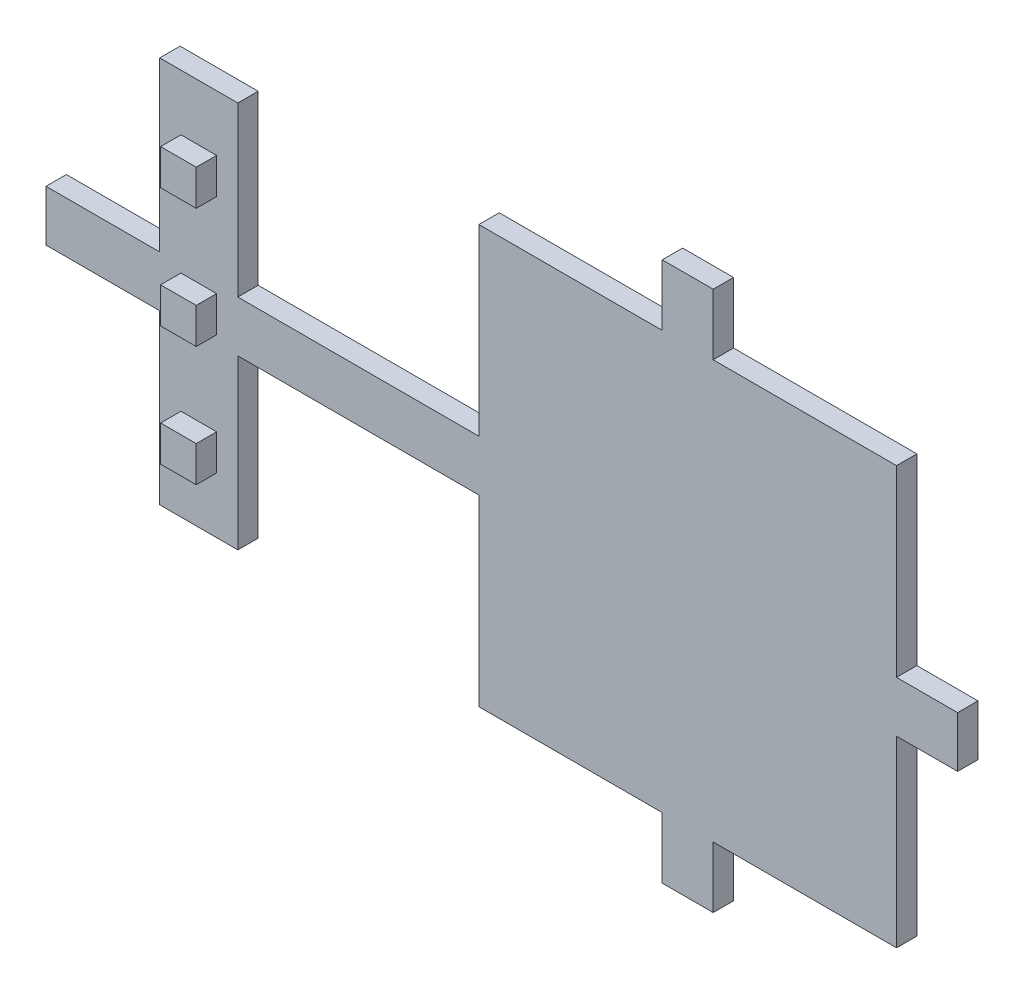
from build123d import *

# Parameters (mm, degrees)
SKETCH1_W           = 82
SKETCH1_H           = 82
BOSS_EXTRUDE3_DEPTH = 4
SKETCH6_W           = 10
SKETCH6_H           = 4
BOSS_EXTRUDE4_DEPTH = 12
CIRPATTERN1_COUNT   = 3
CIRPATTERN1_ANGLE   = 180
SKETCH8_W           = 4
SKETCH8_H           = 10
BOSS_EXTRUDE5_DEPTH = 85
SKETCH12_W          = 15.333160426
SKETCH12_H          = 4
BOSS_EXTRUDE6_DEPTH = 33
SKETCH9_W           = 7
SKETCH9_H           = 7
BOSS_EXTRUDE7_DEPTH = 4
SKETCH13_W          = 7
SKETCH13_H          = 7
BOSS_EXTRUDE8_DEPTH = 4


with BuildPart() as part:
    # Sketch1 → Boss-Extrude3 (new body)
    with BuildSketch(Plane.XY):
        Rectangle(SKETCH1_W, SKETCH1_H)
    extrude(amount=BOSS_EXTRUDE3_DEPTH)

    # Sketch6 → Boss-Extrude4 (add)
    with BuildSketch(Plane(origin=(0, 41, 0), x_dir=(1, 0, 0), z_dir=(0, 1, 0))):
        with Locations((0, -2)):
            Rectangle(SKETCH6_W, SKETCH6_H)
    boss_extrude4 = extrude(amount=BOSS_EXTRUDE4_DEPTH)

    # CirPattern1: Boss-Extrude4 ×3 about axis
    cirpattern1_axis = Axis((0, 0, 4.2), (0, 0, -1))
    for i in range(1, CIRPATTERN1_COUNT):
        add(boss_extrude4.rotate(cirpattern1_axis, i * CIRPATTERN1_ANGLE / (CIRPATTERN1_COUNT - 1)))

    # Sketch8 → Boss-Extrude5 (add)
    with BuildSketch(Plane.ZY.offset(41)):
        with Locations((2, 0)):
            Rectangle(SKETCH8_W, SKETCH8_H)
    extrude(amount=BOSS_EXTRUDE5_DEPTH)

    # Sketch12 → Boss-Extrude6 (add)
    with BuildSketch(Plane(origin=(0, 5, 0), x_dir=(1, 0, 0), z_dir=(0, 1, 0))):
        with Locations((-96, -2)):
            Rectangle(SKETCH12_W, SKETCH12_H)
    boss_extrude6 = extrude(amount=BOSS_EXTRUDE6_DEPTH)

    # Sketch9 → Boss-Extrude7 (add)
    with BuildSketch(Plane.XY.offset(4)):
        with Locations((-96, 0)):
            Rectangle(SKETCH9_W, SKETCH9_H)
    extrude(amount=BOSS_EXTRUDE7_DEPTH)

    # Sketch13 → Boss-Extrude8 (add)
    with BuildSketch(Plane.XY.offset(4)):
        with Locations((-96, 23.5)):
            Rectangle(SKETCH13_W, SKETCH13_H)
    boss_extrude8 = extrude(amount=BOSS_EXTRUDE8_DEPTH)

    # Mirror2: Boss-Extrude6, Boss-Extrude8 across plane
    add(boss_extrude6.mirror(Plane(origin=(0, 0, 0), x_dir=(0, 0, 1), z_dir=(0, -1, 0))))
    add(boss_extrude8.mirror(Plane(origin=(0, 0, 0), x_dir=(0, 0, 1), z_dir=(0, -1, 0))))


solid = part.part
